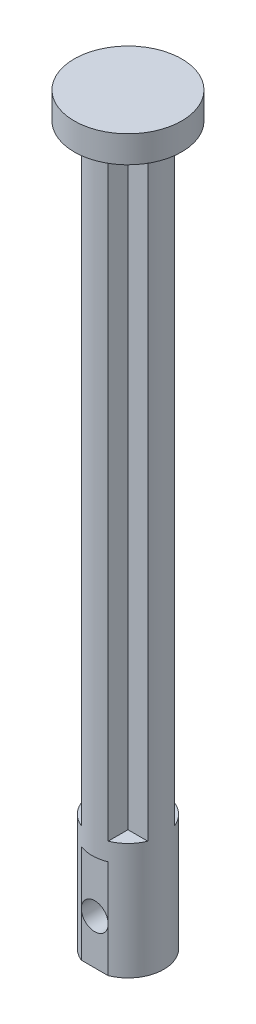
from build123d import *

# Parameters (mm, degrees)
SKETCH1_R           = 4
BOSS_EXTRUDE1_DEPTH = 80
CUT_EXTRUDE1_DEPTH  = 11
SKETCH3_R           = 1.5
CUT_EXTRUDE2_DEPTH  = 4
CUT_EXTRUDE3_DEPTH  = 67
SKETCH5_R           = 6
BOSS_EXTRUDE2_DEPTH = 3


with BuildPart() as part:
    # Sketch1 → Boss-Extrude1 (new body)
    with BuildSketch(Plane(origin=(0, 0, 0), x_dir=(1, 0, 0), z_dir=(0, 1, 0))):
        Circle(SKETCH1_R)
    extrude(amount=BOSS_EXTRUDE1_DEPTH)

    # Sketch2 → Cut-Extrude1 (cut)
    with BuildSketch(Plane.XZ):
        with BuildLine():
            Line((-1.5, 3.708099244), (1.5, 3.708099244))
            ThreePointArc((1.5, 3.708099244), (0, 4), (-1.5, 3.708099244))
        make_face()
    extrude(amount=-CUT_EXTRUDE1_DEPTH, mode=Mode.SUBTRACT)

    # Sketch3 → Cut-Extrude2 (cut)
    with BuildSketch(Plane.XY.offset(3.708099244)):
        with Locations((0, 5)):
            Circle(SKETCH3_R)
    extrude(amount=-CUT_EXTRUDE2_DEPTH, mode=Mode.SUBTRACT)

    # Sketch4 → Cut-Extrude3 (cut)
    with BuildSketch(Plane(origin=(0, 80, 0), x_dir=(1, 0, 0), z_dir=(0, 1, 0))):
        with BuildLine():
            Line((-1.5, -3.586397938), (-1.5, -3.708099244))
            ThreePointArc((-1.5, -3.708099244), (-2.828427125, -2.828427125), (-3.708099244, -1.5))
            Line((-3.708099244, -1.5), (-1.5, -1.5))
            Line((-1.5, -1.5), (-1.5, -3.586397938))
        make_face()
        with BuildLine():
            Line((-3.708099244, 1.5), (-1.5, 1.5))
            Line((-1.5, 1.5), (-1.5, 3.708099244))
            ThreePointArc((-1.5, 3.708099244), (-2.828427125, 2.828427125), (-3.708099244, 1.5))
        make_face()
        with BuildLine():
            Line((1.5, 3.708099244), (1.5, 1.5))
            Line((1.5, 1.5), (3.708099244, 1.5))
            ThreePointArc((3.708099244, 1.5), (2.828427125, 2.828427125), (1.5, 3.708099244))
        make_face()
        with BuildLine():
            Line((1.5, -3.708099244), (1.5, -1.5))
            Line((1.5, -1.5), (3.708099244, -1.5))
            ThreePointArc((3.708099244, -1.5), (2.828427125, -2.828427125), (1.5, -3.708099244))
        make_face()
    extrude(amount=-CUT_EXTRUDE3_DEPTH, mode=Mode.SUBTRACT)

    # Sketch5 → Boss-Extrude2 (add)
    with BuildSketch(Plane(origin=(0, 80, 0), x_dir=(1, 0, 0), z_dir=(0, 1, 0))):
        Circle(SKETCH5_R)
    extrude(amount=BOSS_EXTRUDE2_DEPTH)


solid = part.part
